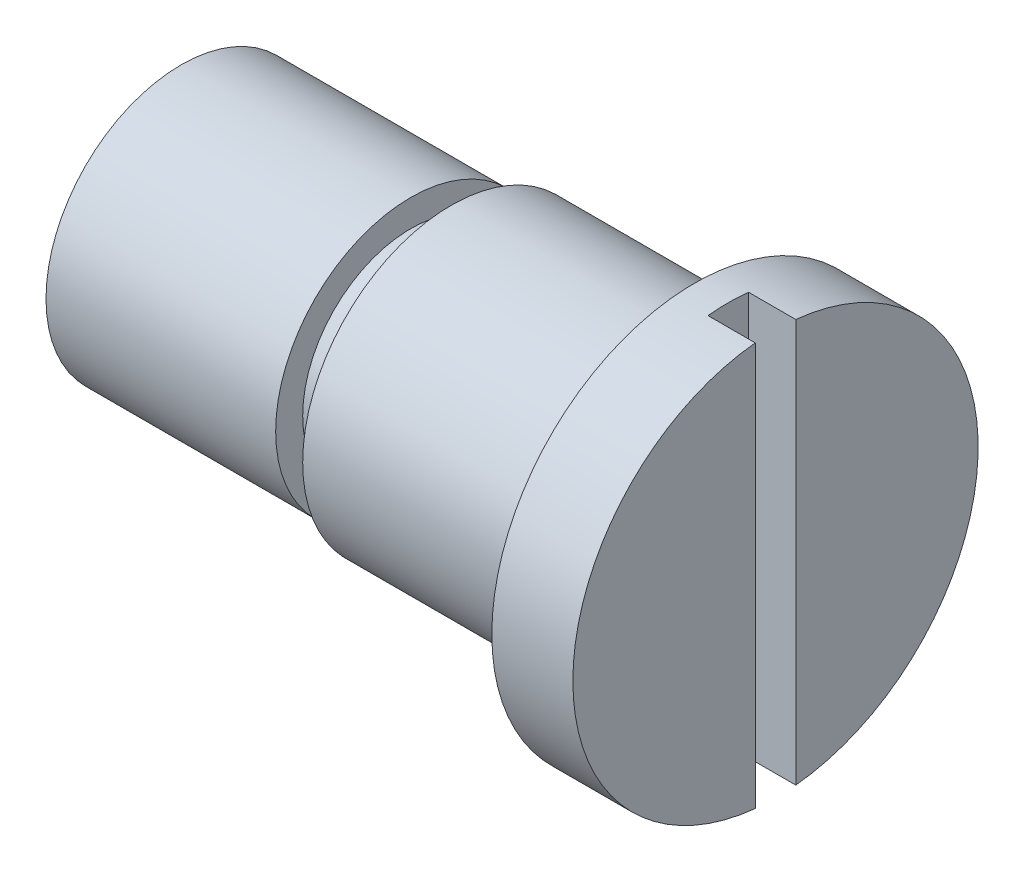
from build123d import *

# Parameters (mm, degrees)
SKETCH2_W          = 3
SKETCH2_H          = 33.9969588
CUT_EXTRUDE1_DEPTH = 3.5


with BuildPart() as part:
    # Sketch1 → Revolve1 (revolve)
    with BuildSketch(Plane.XY):
        Polygon((0, 0), (0, 10), (17, 10), (17, 8), (20, 8), (20, 11), (38, 11), (38, 15), (44, 15), (44, 0), align=None)
    revolve(axis=Axis((0, 0, 0), (1, 0, 0)))

    # Sketch2 → Cut-Extrude1 (cut)
    with BuildSketch(Plane(origin=(44, 0, 0), x_dir=(0, 0, -1), z_dir=(1, 0, 0))):
        Rectangle(SKETCH2_W, SKETCH2_H)
    extrude(amount=-CUT_EXTRUDE1_DEPTH, mode=Mode.SUBTRACT)


solid = part.part
